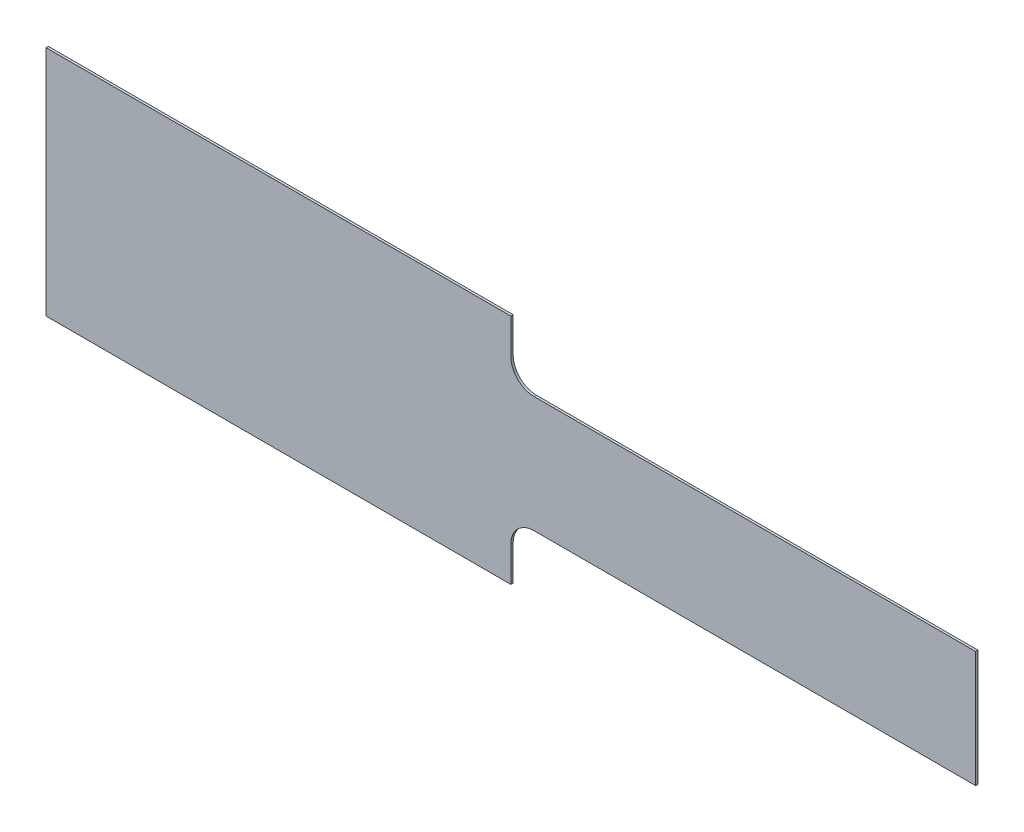
from build123d import *

# Parameters (mm, degrees)
LINEAR_AUSTRAGEN1_DEPTH = 1


with BuildPart() as part:
    # Skizze1 → Linear austragen1 (new body)
    with BuildSketch(Plane.XY):
        with BuildLine():
            Line((0, 50), (200, 50))
            Line((200, 50), (200, 35))
            ThreePointArc((200, 35), (202.928932188, 27.928932188), (210, 25))
            Line((210, 25), (400, 25))
            Line((400, 25), (400, -25))
            Line((400, -25), (210, -25))
            ThreePointArc((210, -25), (202.928932188, -27.928932188), (200, -35))
            Line((200, -35), (200, -50))
            Line((200, -50), (0, -50))
            Line((0, -50), (0, 50))
        make_face()
    extrude(amount=LINEAR_AUSTRAGEN1_DEPTH)


solid = part.part
